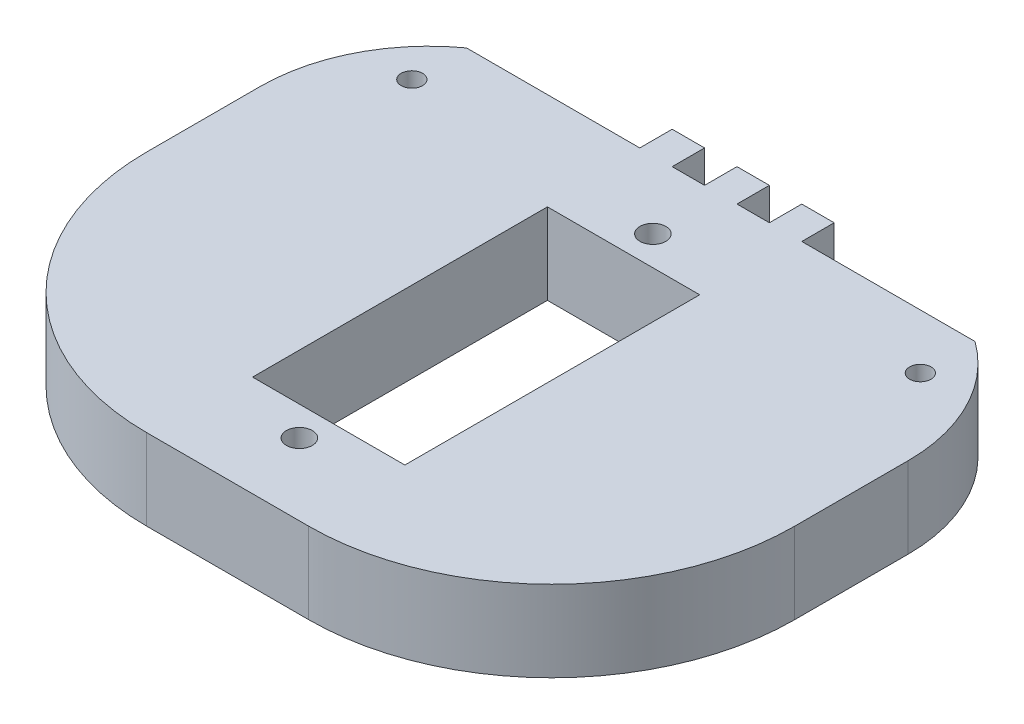
from build123d import *

# Parameters (mm, degrees)
SKETCH2_R           = 0.840105
SKETCH2_R_2         = 1.016
BOSS_EXTRUDE2_DEPTH = 6.35


with BuildPart() as part:
    # Sketch2 → Boss-Extrude2 (new body)
    with BuildSketch(Plane(origin=(0, 0, 0), x_dir=(1, 0, 0), z_dir=(0, 1, 0))):
        with BuildLine():
            Line((19.05, -6.35), (31.75, -6.35))
            ThreePointArc((31.75, -6.35), (45.220384182, -0.770384182), (50.8, 12.7))
            Line((50.8, 12.7), (50.8, 21.59))
            ThreePointArc((50.8, 21.59), (49.353345536, 27.604748069), (45.329825459, 32.303821346))
            Line((45.329825459, 32.303821346), (31.75, 32.303821346))
            Line((31.75, 32.303821346), (31.75, 34.843821346))
            Line((31.75, 34.843821346), (29.21, 34.843821346))
            Line((29.21, 34.843821346), (29.21, 32.303821346))
            Line((29.21, 32.303821346), (26.67, 32.303821346))
            Line((26.67, 32.303821346), (26.67, 34.843821346))
            Line((26.67, 34.843821346), (24.13, 34.843821346))
            Line((24.13, 34.843821346), (24.13, 32.303821346))
            Line((24.13, 32.303821346), (21.59, 32.303821346))
            Line((21.59, 32.303821346), (21.59, 34.843821346))
            Line((21.59, 34.843821346), (19.05, 34.843821346))
            Line((19.05, 34.843821346), (19.05, 32.303821346))
            Line((19.05, 32.303821346), (5.470174541, 32.303821346))
            ThreePointArc((5.470174541, 32.303821346), (1.446654464, 27.604748069), (0, 21.59))
            Line((0, 21.59), (0, 12.7))
            ThreePointArc((0, 12.7), (5.579615818, -0.770384182), (19.05, -6.35))
        make_face()
        with Locations((45.329825459, 28.017571346)):
            Circle(SKETCH2_R, mode=Mode.SUBTRACT)
        with Locations((25.4, 26.983791346)):
            Circle(SKETCH2_R_2, mode=Mode.SUBTRACT)
        with Locations((5.47017448, 28.017571346)):
            Circle(SKETCH2_R, mode=Mode.SUBTRACT)
        with Locations((25.4, -0.730148654)):
            Circle(SKETCH2_R_2, mode=Mode.SUBTRACT)
        Polygon((25.4, 24.683821346), (31.369, 24.683821346), (31.369, 1.569821346), (19.431, 1.569821346), (19.431, 24.683821346), align=None, mode=Mode.SUBTRACT)
    extrude(amount=BOSS_EXTRUDE2_DEPTH)


solid = part.part
